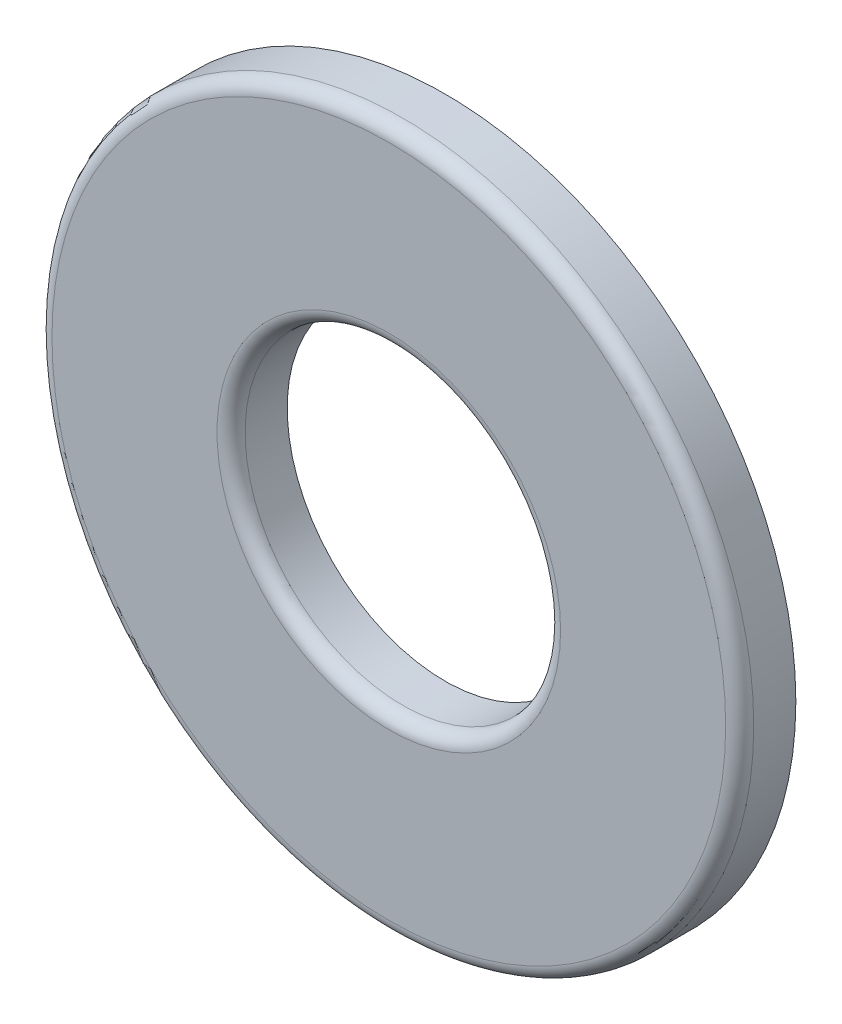
from build123d import *

# Parameters (mm, degrees)
SKETCH3_R                = 7.9375
SKETCH3_R_2              = 3.5687
BOSS_EXTRUDE1_DEPTH      = 0.635
BOSS_EXTRUDE1_DEPTH_BACK = 0.635
FILLET1_R                = 0.3175


with BuildPart() as part:
    # Sketch3 → Boss-Extrude1 (new body, two sides)
    with BuildSketch(Plane.XY) as boss_extrude1_sk:
        Circle(SKETCH3_R)
        Circle(SKETCH3_R_2, mode=Mode.SUBTRACT)
    extrude(amount=BOSS_EXTRUDE1_DEPTH)
    extrude(boss_extrude1_sk.sketch, amount=-BOSS_EXTRUDE1_DEPTH_BACK)

    # Fillet1
    fillet1_edges = [part.edges().sort_by_distance(p)[0] for p in [
        (-7.9375, 0, 0.635),
        (-3.5687, 0, 0.635),
    ]]
    fillet(fillet1_edges, radius=FILLET1_R)


solid = part.part
